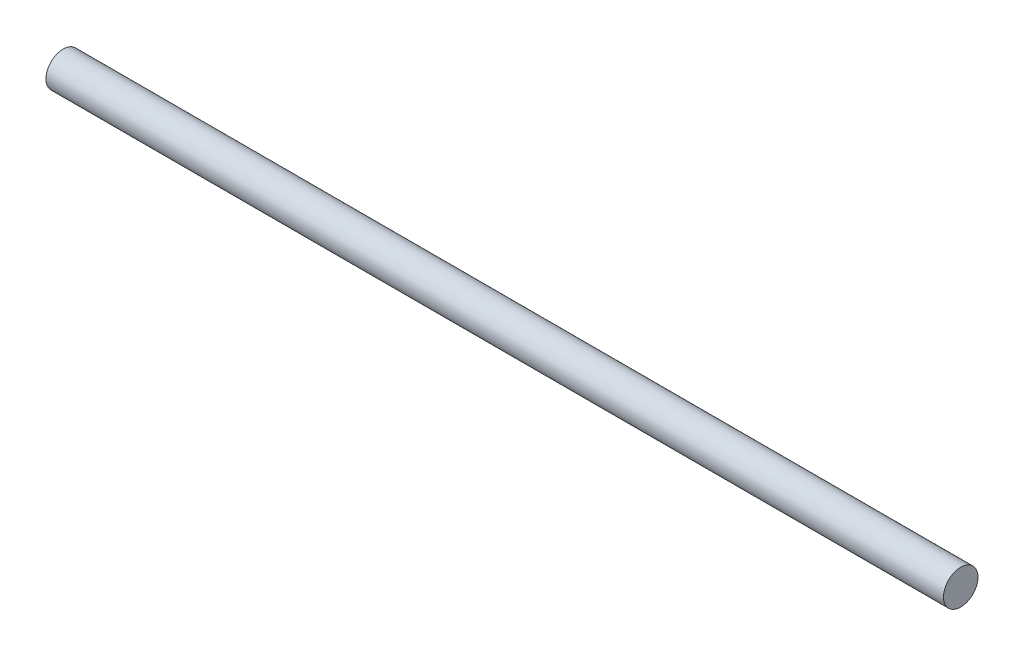
from build123d import *

# Parameters (mm, degrees)
SKETCH1_R           = 6.35
BOSS_EXTRUDE1_DEPTH = 330.2


with BuildPart() as part:
    # Sketch1 → Boss-Extrude1 (new body)
    with BuildSketch(Plane(origin=(0, 0, 0), x_dir=(0, 0, -1), z_dir=(1, 0, 0))):
        Circle(SKETCH1_R)
    extrude(amount=BOSS_EXTRUDE1_DEPTH)


solid = part.part
